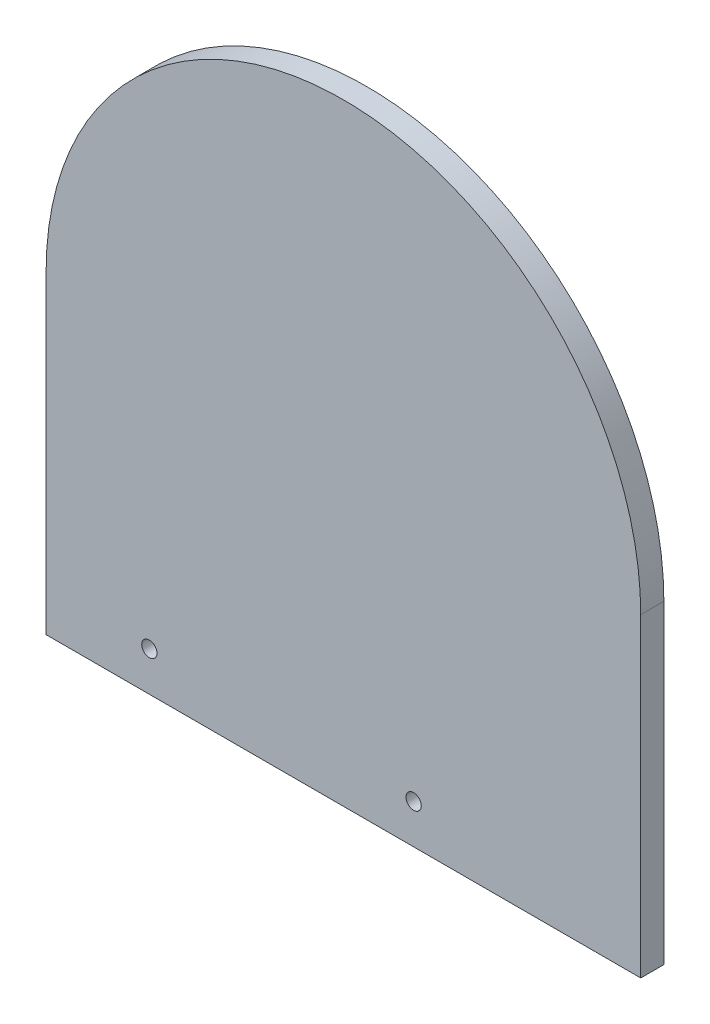
from build123d import *

# Parameters (mm, degrees)
SKETCH1_R           = 1.85
BOSS_EXTRUDE1_DEPTH = 5.6


with BuildPart() as part:
    # Sketch1 → Boss-Extrude1 (new body)
    with BuildSketch(Plane.XY):
        with BuildLine():
            Line((-72, 0), (72, 0))
            Line((72, 0), (72, 76.2))
            ThreePointArc((72, 76.2), (0, 148.2), (-72, 76.2))
            Line((-72, 76.2), (-72, 0))
        make_face()
        with Locations((-47, 9.525)):
            Circle(SKETCH1_R, mode=Mode.SUBTRACT)
        with Locations((17, 9.525)):
            Circle(SKETCH1_R, mode=Mode.SUBTRACT)
    extrude(amount=BOSS_EXTRUDE1_DEPTH)


solid = part.part
